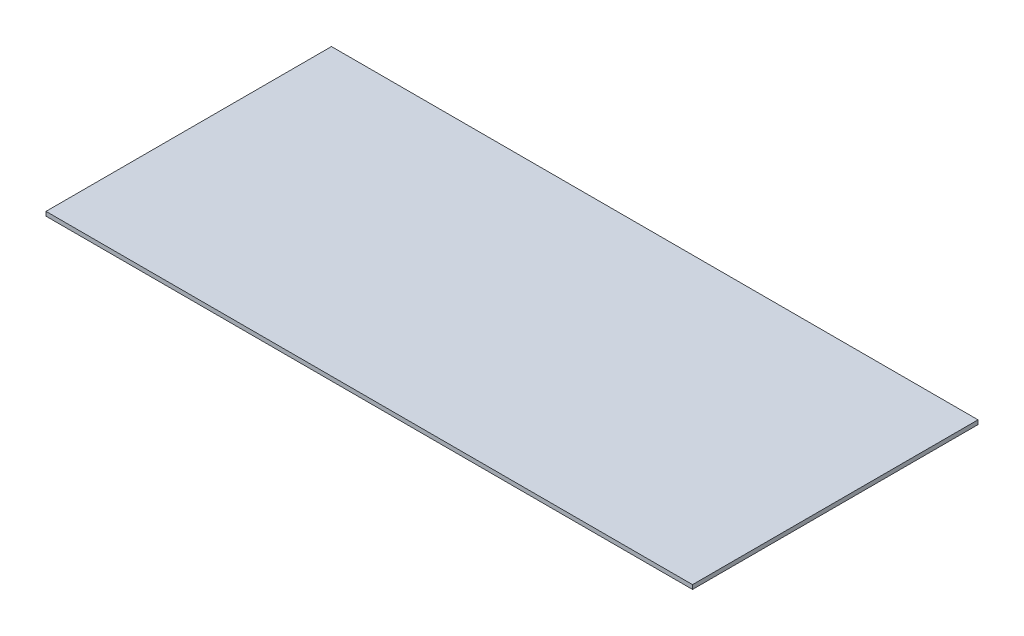
from build123d import *

# Parameters (mm, degrees)
SKETCH1_W   = 977.9
SKETCH1_H   = 431.8
GLASS_DEPTH = 6.35


with BuildPart() as part:
    # Sketch1 → Glass (new body)
    with BuildSketch(Plane(origin=(0, 0, 0), x_dir=(1, 0, 0), z_dir=(0, 1, 0))):
        Rectangle(SKETCH1_W, SKETCH1_H)
    extrude(amount=GLASS_DEPTH)


solid = part.part
